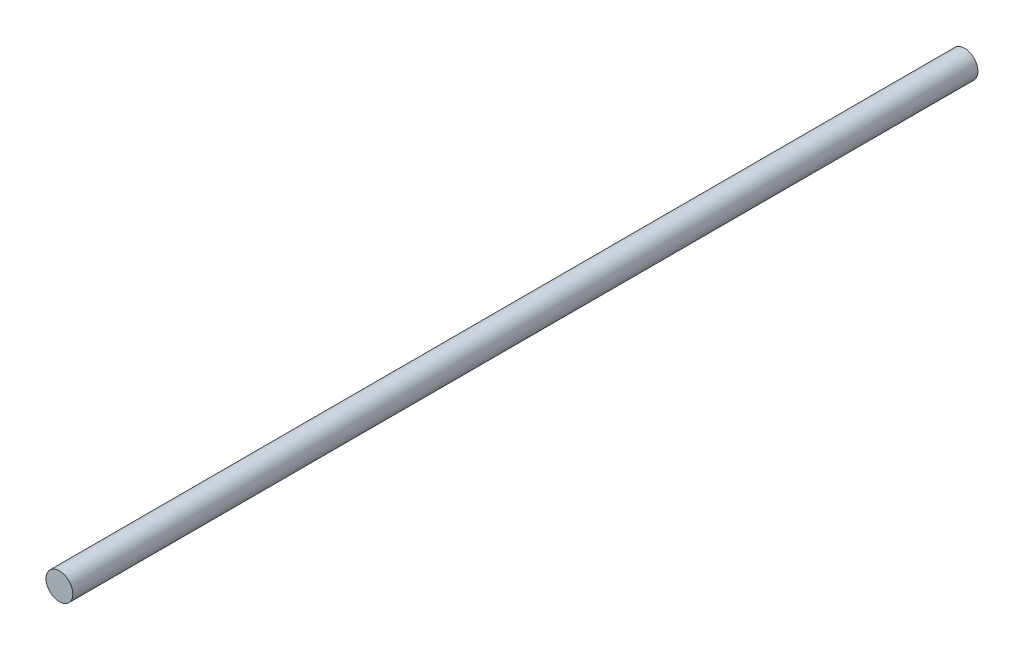
from build123d import *

# Parameters (mm, degrees)
SKETCH1_R           = 4.7625
BOSS_EXTRUDE1_DEPTH = 321.31


with BuildPart() as part:
    # Sketch1 → Boss-Extrude1 (new body)
    with BuildSketch(Plane.XY):
        Circle(SKETCH1_R)
    extrude(amount=BOSS_EXTRUDE1_DEPTH)


solid = part.part
